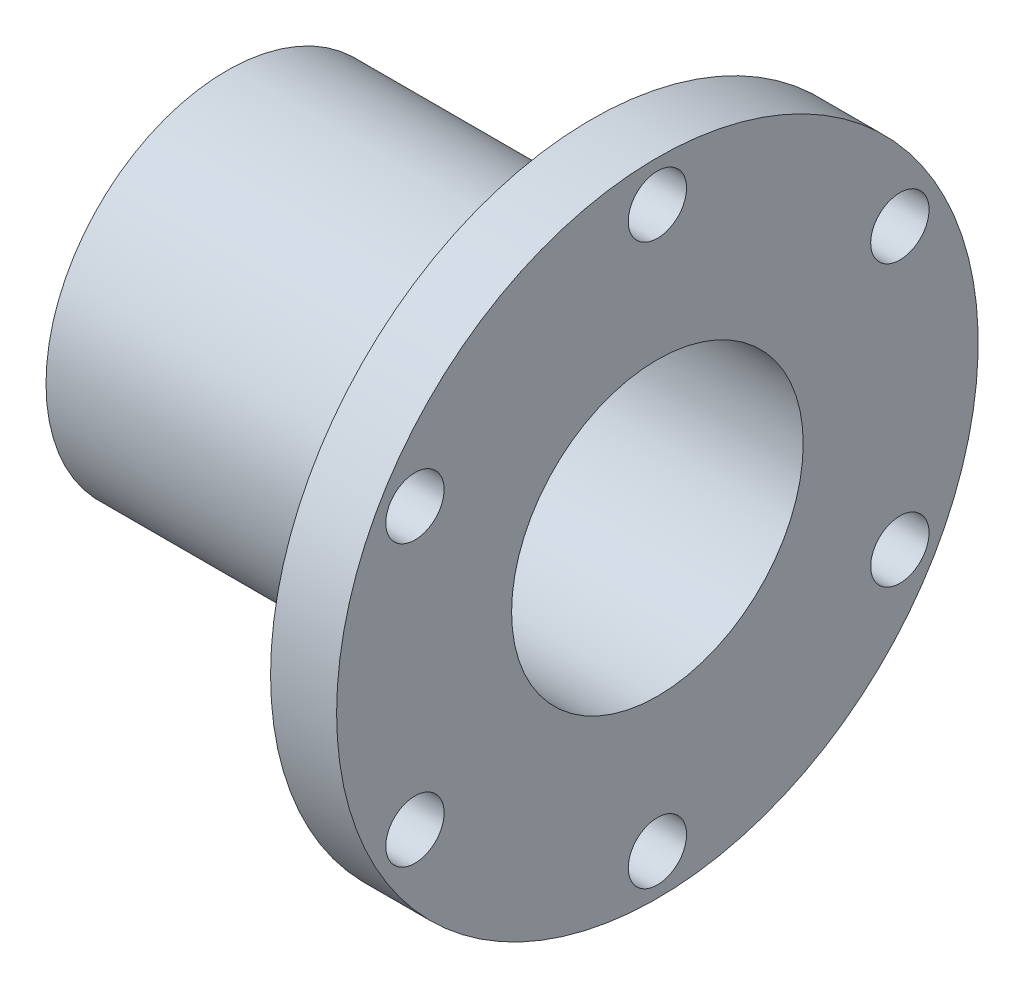
from build123d import *

# Parameters (mm, degrees)
SKETCH2_R          = 10
CUT_EXTRUDE1_DEPTH = 30
CIRPATTERN1_COUNT  = 6


with BuildPart() as part:
    # Sketch1 → Revolve1 (revolve)
    with BuildSketch(Plane.XY):
        Polygon((-147.64573991, 50), (0, 50), (0, 110), (-22.64573991, 110), (-22.64573991, 62), (-147.64573991, 62), align=None)
    revolve(axis=Axis((-203.3632287, 0, 0), (1, 0, 0)))

    # Sketch2 → Cut-Extrude1 (cut)
    with BuildSketch(Plane(origin=(0, 0, 0), x_dir=(0, 0, -1), z_dir=(1, 0, 0))):
        with Locations((0, 96)):
            Circle(SKETCH2_R)
    cut_extrude1 = extrude(amount=-CUT_EXTRUDE1_DEPTH, mode=Mode.SUBTRACT)

    # CirPattern1: Cut-Extrude1 ×6 about axis
    cirpattern1_axis = Axis((0, 0, 0), (1, 0, 0))
    for i in range(1, CIRPATTERN1_COUNT):
        add(cut_extrude1.rotate(cirpattern1_axis, i * 360 / CIRPATTERN1_COUNT), mode=Mode.SUBTRACT)


solid = part.part
